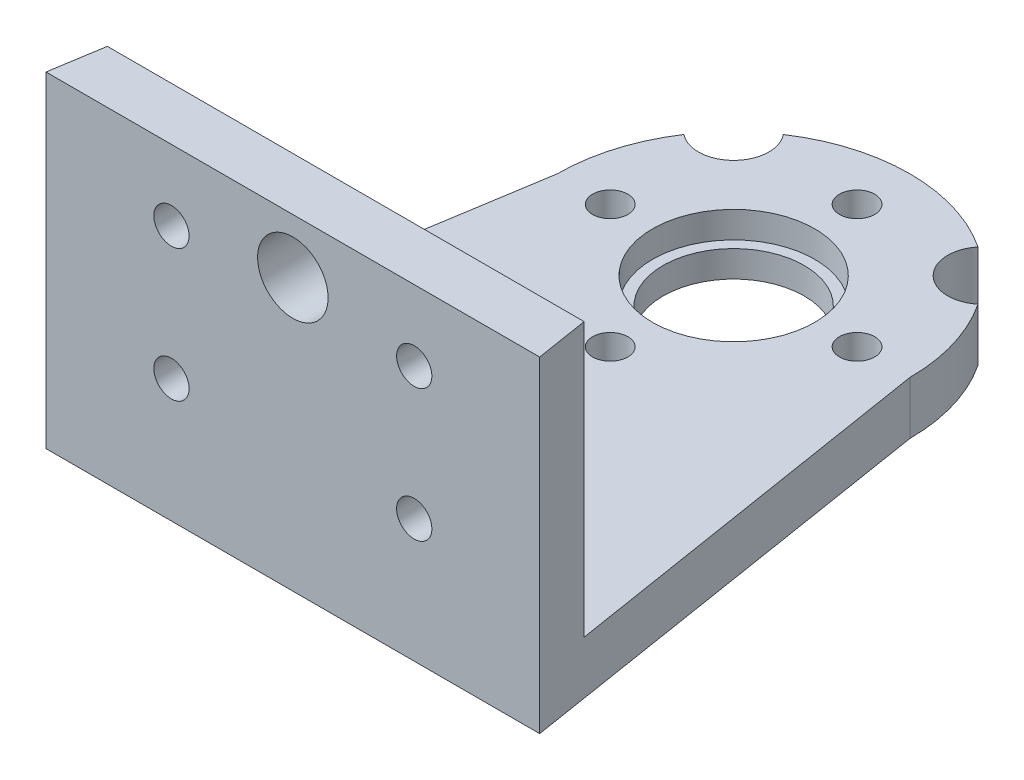
from build123d import *

# Parameters (mm, degrees)
BOSS_EXTRUDE1_DEPTH = 3
SKETCH2_R           = 4
CUT_EXTRUDE1_DEPTH  = 13
SKETCH4_R           = 1
CUT_EXTRUDE3_DEPTH  = 3
BOSS_EXTRUDE2_DEPTH = 15.5
SKETCH6_R           = 4.6
CUT_EXTRUDE4_DEPTH  = 1.5
SKETCH7_R           = 2
CUT_EXTRUDE5_DEPTH  = 10
SKETCH8_R           = 1
CUT_EXTRUDE6_DEPTH  = 10
SKETCH9_R           = 2
CUT_EXTRUDE7_DEPTH  = 10


with BuildPart() as part:
    # Sketch1 → Boss-Extrude1 (new body)
    with BuildSketch(Plane(origin=(0, 0, 0), x_dir=(1, 0, 0), z_dir=(0, 1, 0))):
        with BuildLine():
            Line((-10, 0), (-14, -25))
            Line((-14, -25), (14, -25))
            Line((14, -25), (10, 0))
            ThreePointArc((10, 0), (0, 10), (-10, 0))
        make_face()
    extrude(amount=BOSS_EXTRUDE1_DEPTH)

    # Sketch2 → Cut-Extrude1 (cut)
    with BuildSketch(Plane(origin=(0, 3, 0), x_dir=(1, 0, 0), z_dir=(0, 1, 0))):
        Circle(SKETCH2_R)
    extrude(amount=-CUT_EXTRUDE1_DEPTH, mode=Mode.SUBTRACT)

    # Sketch4 → Cut-Extrude3 (cut)
    with BuildSketch(Plane(origin=(0, 3, 0), x_dir=(1, 0, 0), z_dir=(0, 1, 0))):
        with Locations((0, -7)):
            Circle(SKETCH4_R)
        with Locations((-7, 0)):
            Circle(SKETCH4_R)
        with Locations((0, 7)):
            Circle(SKETCH4_R)
        with Locations((7, 0)):
            Circle(SKETCH4_R)
    extrude(amount=-CUT_EXTRUDE3_DEPTH, mode=Mode.SUBTRACT)

    # Sketch5 → Boss-Extrude2 (add)
    with BuildSketch(Plane(origin=(0, 3, 0), x_dir=(1, 0, 0), z_dir=(0, 1, 0))):
        Polygon((-13.52, -22), (13.52, -22), (14, -25), (-14, -25), align=None)
    extrude(amount=BOSS_EXTRUDE2_DEPTH)

    # Sketch6 → Cut-Extrude4 (cut)
    with BuildSketch(Plane(origin=(0, 3, 0), x_dir=(1, 0, 0), z_dir=(0, 1, 0))):
        Circle(SKETCH6_R)
    extrude(amount=-CUT_EXTRUDE4_DEPTH, mode=Mode.SUBTRACT)

    # Sketch7 → Cut-Extrude5 (cut)
    with BuildSketch(Plane(origin=(0, 3, 0), x_dir=(1, 0, 0), z_dir=(0, 1, 0))):
        with Locations((-7.071067812, 7.071067812)):
            Circle(SKETCH7_R)
        with Locations((7.071067812, 7.071067812)):
            Circle(SKETCH7_R)
    extrude(amount=-CUT_EXTRUDE5_DEPTH, mode=Mode.SUBTRACT)

    # Sketch8 → Cut-Extrude6 (cut)
    with BuildSketch(Plane(origin=(0, 0, 22), x_dir=(-1, 0, 0), z_dir=(0, 0, -1))):
        with Locations((6.885, 7)):
            Circle(SKETCH8_R)
        with Locations((-6.885, 7)):
            Circle(SKETCH8_R)
        with Locations((6.885, 14.5)):
            Circle(SKETCH8_R)
        with Locations((-6.885, 14.5)):
            Circle(SKETCH8_R)
    extrude(amount=-CUT_EXTRUDE6_DEPTH, mode=Mode.SUBTRACT)

    # Sketch9 → Cut-Extrude7 (cut)
    with BuildSketch(Plane(origin=(0, 0, 22), x_dir=(-1, 0, 0), z_dir=(0, 0, -1))):
        with Locations((0, 15.4)):
            Circle(SKETCH9_R)
    extrude(amount=-CUT_EXTRUDE7_DEPTH, mode=Mode.SUBTRACT)


solid = part.part
